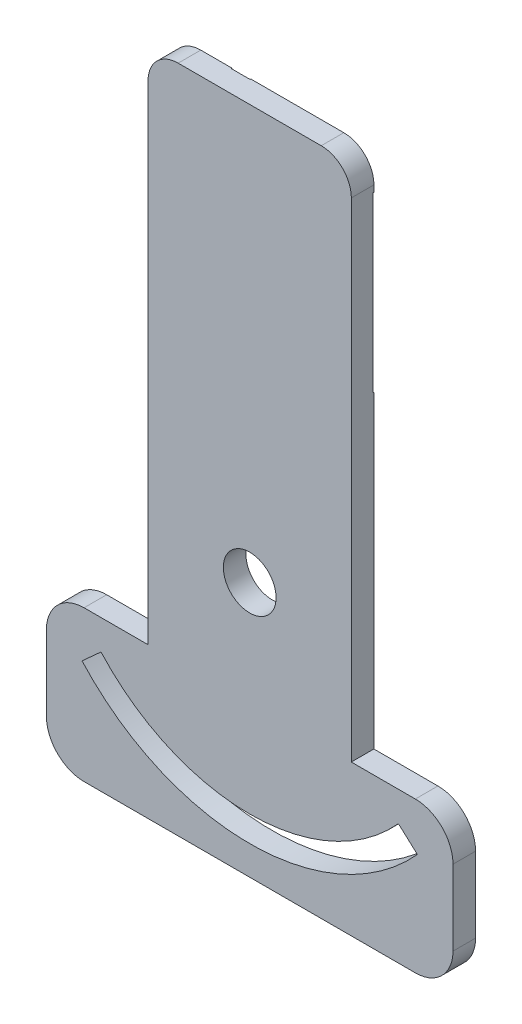
from build123d import *

# Parameters (mm, degrees)
CORTE_EXTERIOR_R        = 3.500001168
SALIENTE_EXTRUIR1_DEPTH = 3
CORTAR_EXTRUIR1_DEPTH   = 1
CORTAR_EXTRUIR2_DEPTH   = 0.1


with BuildPart() as part:
    # Corte exterior → Saliente-Extruir1 (new body)
    with BuildSketch(Plane.XY):
        with BuildLine():
            Line((19.521996462, -6.085833738), (11.021996462, -6.085833738))
            ThreePointArc((11.021996462, -6.085833738), (7.486462556, -7.550299832), (6.021996462, -11.085833738))
            Line((6.021996462, -11.085833738), (6.021996462, -21.085833738))
            ThreePointArc((6.021996462, -21.085833738), (7.486462556, -24.621367644), (11.021996462, -26.085833738))
            Line((11.021996462, -26.085833738), (55.021996462, -26.085833738))
            ThreePointArc((55.021996462, -26.085833738), (58.557530368, -24.621367644), (60.021996462, -21.085833738))
            Line((60.021996462, -21.085833738), (60.021996462, -11.085833738))
            ThreePointArc((60.021996462, -11.085833738), (58.557530368, -7.550299832), (55.021996462, -6.085833738))
            Line((55.021996462, -6.085833738), (46.514841363, -6.085833738))
            Line((46.514841363, -6.085833738), (46.521996462, 58.812041738))
            ThreePointArc((46.521996462, 58.812041738), (45.350423587, 61.640468863), (42.521996462, 62.812041738))
            Line((42.521996462, 62.812041738), (23.521996462, 62.812041738))
            ThreePointArc((23.521996462, 62.812041738), (20.693569337, 61.640468863), (19.521996462, 58.812041738))
            Line((19.521996462, 58.812041738), (19.521996462, -6.085833738))
        make_face()
        with Locations((33.021996462, 7.812041474)):
            Circle(CORTE_EXTERIOR_R, mode=Mode.SUBTRACT)
        with BuildLine():
            Line((55.29494797, -12.330366391), (52.77320204, -10.049840692))
            ThreePointArc((52.77320204, -10.049840692), (33.021996462, -18.817961696), (13.270789317, -10.049842109))
            Line((13.270789317, -10.049842109), (10.749043386, -12.330367808))
            ThreePointArc((10.749043386, -12.330367808), (33.021996462, -22.217961696), (55.29494797, -12.330366391))
        make_face(mode=Mode.SUBTRACT)
    extrude(amount=SALIENTE_EXTRUIR1_DEPTH)

    # Grabado Superficie → Cortar-Extruir1 (cut)
    with BuildSketch(Plane.XY):
        with BuildLine():
            Line((35.89134848, 9.816243852), (35.017032688, 22.202862127))
            ThreePointArc((35.017032688, 22.202862127), (33.021996462, 24.062041474), (31.026960236, 22.202862127))
            Line((31.026960236, 22.202862127), (30.152644444, 9.816243852))
            ThreePointArc((30.152644444, 9.816243852), (33.021996462, 11.312042642), (35.89134848, 9.816243852))
        make_face()
    extrude(amount=CORTAR_EXTRUIR1_DEPTH, mode=Mode.SUBTRACT)

    # grabado linea medio → Cortar-Extruir2 (cut)
    with BuildSketch(Plane.XY):
        Polygon((23.601996462, 43.022041738), (19.521996462, 43.022041738), (19.521996462, 58.172041738), (27.661996462, 58.172041738), (27.661996462, 62.812041738), (30.181996462, 62.812041738), (30.181996462, 58.170825238), (46.521996462, 57.970825238), (46.521996462, 34.942041738), (30.181996462, 34.942041738), (30.181996462, 30.302041738), (27.661996462, 30.302041738), (27.661996462, 34.942041738), (23.601996462, 34.942041738), align=None)
    extrude(amount=CORTAR_EXTRUIR2_DEPTH, mode=Mode.SUBTRACT)


solid = part.part
